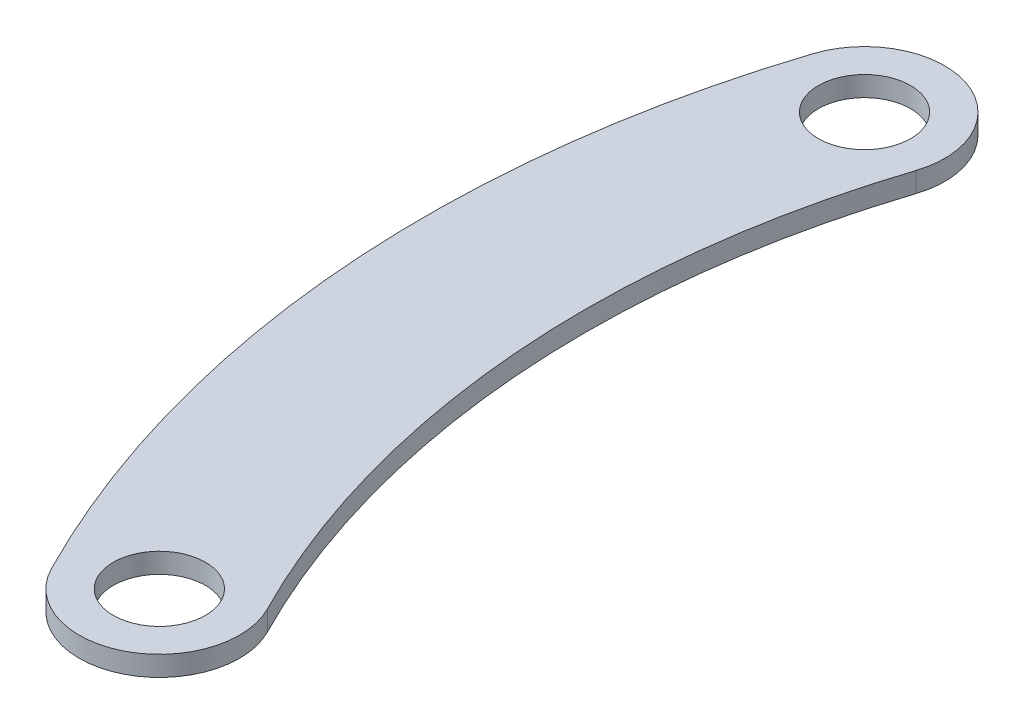
from build123d import *

# Parameters (mm, degrees)
SKETCH1_R           = 6
BOSS_EXTRUDE1_DEPTH = 3
SCALE1_SCALE        = 0.225
CUT_EXTRUDE2_REACH  = 2.675
SKETCH3_R           = 1.55


with BuildPart() as part:
    # Sketch1 → Boss-Extrude1 (new body)
    with BuildSketch(Plane(origin=(0, 0, 0), x_dir=(1, 0, 0), z_dir=(0, 1, 0))):
        with BuildLine():
            ThreePointArc((-154.074297715, 50.051081743), (-161.4998099, -12.720511087), (-144.338440027, -73.555521415))
            ThreePointArc((-144.338440027, -73.555521415), (-128.198146587, -78.798700571), (-122.95496743, -62.658407131))
            ThreePointArc((-122.95496743, -62.658407131), (-137.573912137, -10.835990926), (-131.248475831, 42.63610667))
            ThreePointArc((-131.248475831, 42.63610667), (-138.953899237, 57.756505148), (-154.074297715, 50.051081743))
        make_face()
        with Locations((-142.661386773, 46.343594206)):
            Circle(SKETCH1_R, mode=Mode.SUBTRACT)
        with Locations((-133.646703729, -68.106964273)):
            Circle(SKETCH1_R, mode=Mode.SUBTRACT)
    extrude(amount=BOSS_EXTRUDE1_DEPTH)


with BuildPart() as part_1:
    # Scale1: scaled about (-145.162315364, 1.5, 11.433690498)
    add(part.part.scale(SCALE1_SCALE).moved(Location((-112.500794407, 1.1625, 8.861110136))))

    # Sketch3 → Cut-Extrude2 (cut, up to next)
    with BuildSketch(Plane(origin=(0, 1.8375, 0), x_dir=(1, 0, 0), z_dir=(0, 1, 0)), mode=Mode.PRIVATE) as cut_extrude2_sk1:
        with Locations((-144.599606431, 1.56619856)):
            Circle(SKETCH3_R)
    cut_extrude2_tool1 = extrude(cut_extrude2_sk1.sketch, amount=-CUT_EXTRUDE2_REACH, mode=Mode.PRIVATE) & part_1.part
    add(cut_extrude2_tool1.solids().sort_by_distance((-144.599606, 1.8375, -1.566199))[0], mode=Mode.SUBTRACT)
    # Sketch3 → Cut-Extrude2 (cut, up to next)
    with BuildSketch(Plane(origin=(0, 1.8375, 0), x_dir=(1, 0, 0), z_dir=(0, 1, 0)), mode=Mode.PRIVATE) as cut_extrude2_sk2:
        with Locations((-142.571302746, -24.185177098)):
            Circle(SKETCH3_R)
    cut_extrude2_tool2 = extrude(cut_extrude2_sk2.sketch, amount=-CUT_EXTRUDE2_REACH, mode=Mode.PRIVATE) & part_1.part
    add(cut_extrude2_tool2.solids().sort_by_distance((-142.571303, 1.8375, 24.185177))[0], mode=Mode.SUBTRACT)


solid = part_1.part
